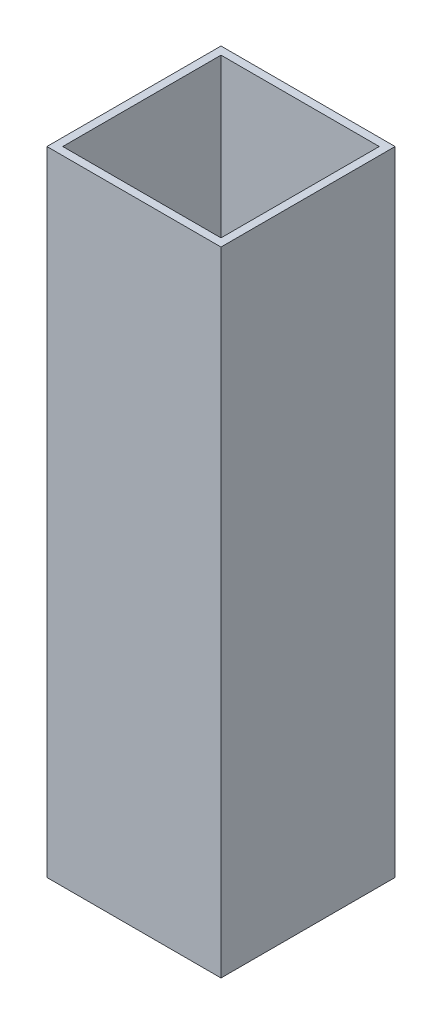
from build123d import *

# Parameters (mm, degrees)
SKETCH1_W           = 11
SKETCH1_H           = 11
BOSS_EXTRUDE2_DEPTH = 40
SHELL1_T            = -0.5


with BuildPart() as part:
    # Sketch1 → Boss-Extrude2 (new body)
    with BuildSketch(Plane(origin=(0, 0, 0), x_dir=(1, 0, 0), z_dir=(0, 1, 0))):
        with Locations((-5.140487805, 5.014390244)):
            Rectangle(SKETCH1_W, SKETCH1_H)
    extrude(amount=BOSS_EXTRUDE2_DEPTH)

    # Shell1
    shell1_openings = [part.faces().sort_by_distance(p)[0] for p in [
        (-5.140487805, 40, -5.014390244),
    ]]
    offset(amount=SHELL1_T, openings=shell1_openings, kind=Kind.INTERSECTION)


solid = part.part
